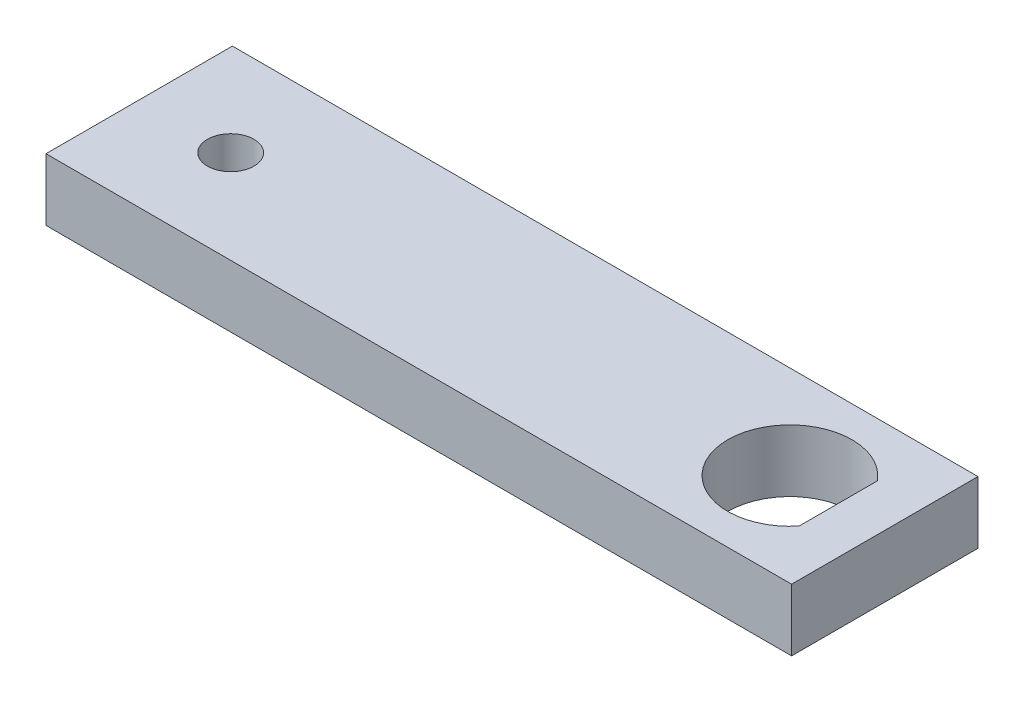
from build123d import *

# Parameters (mm, degrees)
SKETCH1_W           = 76.2
SKETCH1_H           = 19.05
SKETCH1_R           = 2.38
BOSS_EXTRUDE1_DEPTH = 6.35


with BuildPart() as part:
    # Sketch1 → Boss-Extrude1 (new body)
    with BuildSketch(Plane(origin=(0, 0, 0), x_dir=(1, 0, 0), z_dir=(0, 1, 0))):
        with Locations((0, 9.525)):
            Rectangle(SKETCH1_W, SKETCH1_H)
        with Locations((-28.75, 9.525)):
            Circle(SKETCH1_R, mode=Mode.SUBTRACT)
        with BuildLine():
            Line((33.34, 13.514849621), (33.34, 5.535150379))
            ThreePointArc((33.34, 5.535150379), (22.05, 9.525), (33.34, 13.514849621))
        make_face(mode=Mode.SUBTRACT)
    extrude(amount=BOSS_EXTRUDE1_DEPTH)


solid = part.part
